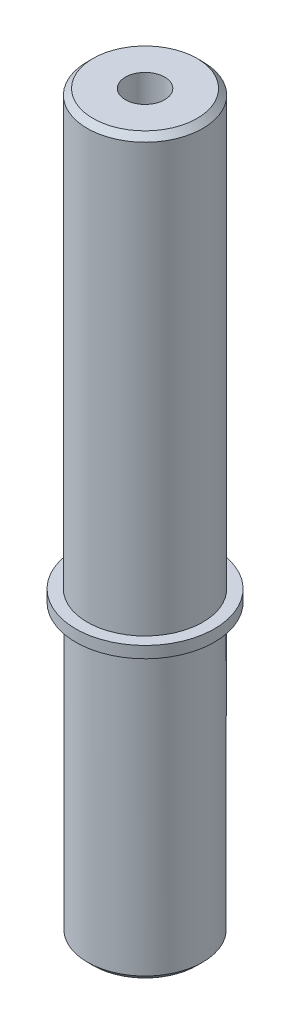
from build123d import *

# Parameters (mm, degrees)
CHAMFER1_SIZE     = 1
M8_TAPPED_HOLE1_D = 6.8


with BuildPart() as part:
    # Sketch1 → Revolve1 (revolve)
    with BuildSketch(Plane(origin=(0, 0, 0), x_dir=(0, 0, -1), z_dir=(1, 0, 0))):
        Polygon((0, 0), (0, 127), (-10, 127), (-10, 52), (-12, 52), (-12, 50), (-9.95, 50), (-9.95, 0), align=None)
    revolve(axis=Axis((0, 0, 0), (0, 1, 0)))

    # Chamfer1
    chamfer1_edges = [part.edges().sort_by_distance(p)[0] for p in [
        (0, 0, -9.95),
        (0, 127, -10),
    ]]
    chamfer(chamfer1_edges, length=CHAMFER1_SIZE)

    # M8 Tapped Hole1 (through all)
    with Locations(Plane(origin=(0, 127, 0), x_dir=(1, 0, 0), z_dir=(0, 1, 0))):
        with Locations((0, 0)):
            Hole(M8_TAPPED_HOLE1_D / 2)


solid = part.part
